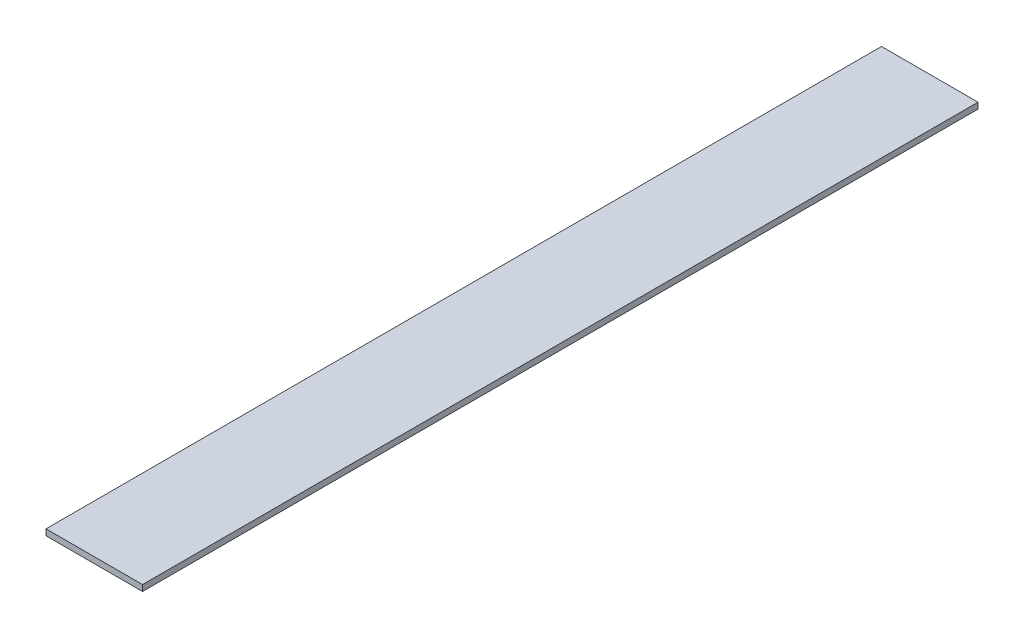
from build123d import *

# Parameters (mm, degrees)
SKETCH1_W           = 50.8
SKETCH1_H           = 439.7375
BOSS_EXTRUDE1_DEPTH = 3.175


with BuildPart() as part:
    # Sketch1 → Boss-Extrude1 (new body)
    with BuildSketch(Plane(origin=(0, 0, 0), x_dir=(1, 0, 0), z_dir=(0, 1, 0))):
        Rectangle(SKETCH1_W, SKETCH1_H)
    extrude(amount=BOSS_EXTRUDE1_DEPTH)


solid = part.part
